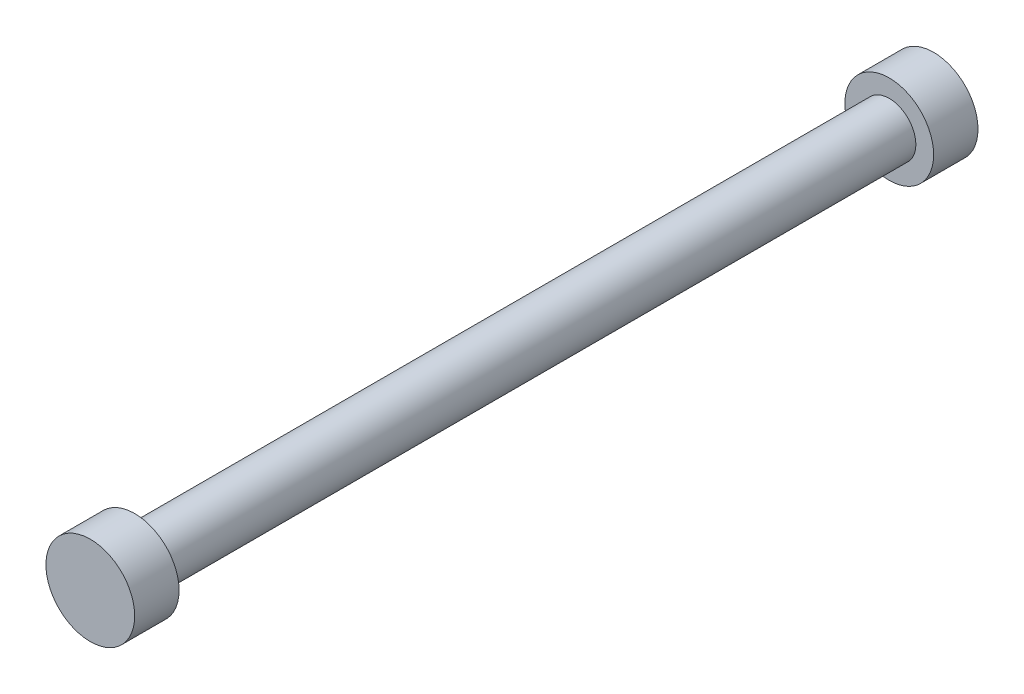
from build123d import *

# Parameters (mm, degrees)
SKETCH1_R           = 3
BOSS_EXTRUDE1_DEPTH = 42.5
SKETCH2_R           = 5
BOSS_EXTRUDE2_DEPTH = 5


with BuildPart() as part:
    # Sketch1 → Boss-Extrude1 (new body, symmetric)
    with BuildSketch(Plane.XY):
        Circle(SKETCH1_R)
    extrude(amount=BOSS_EXTRUDE1_DEPTH, both=True)

    # Sketch2 → Boss-Extrude2 (add)
    with BuildSketch(Plane.XY.offset(42.5)):
        Circle(SKETCH2_R)
    boss_extrude2 = extrude(amount=BOSS_EXTRUDE2_DEPTH)

    # Mirror1: Boss-Extrude2 across plane
    add(boss_extrude2.mirror(Plane.XY))


solid = part.part
